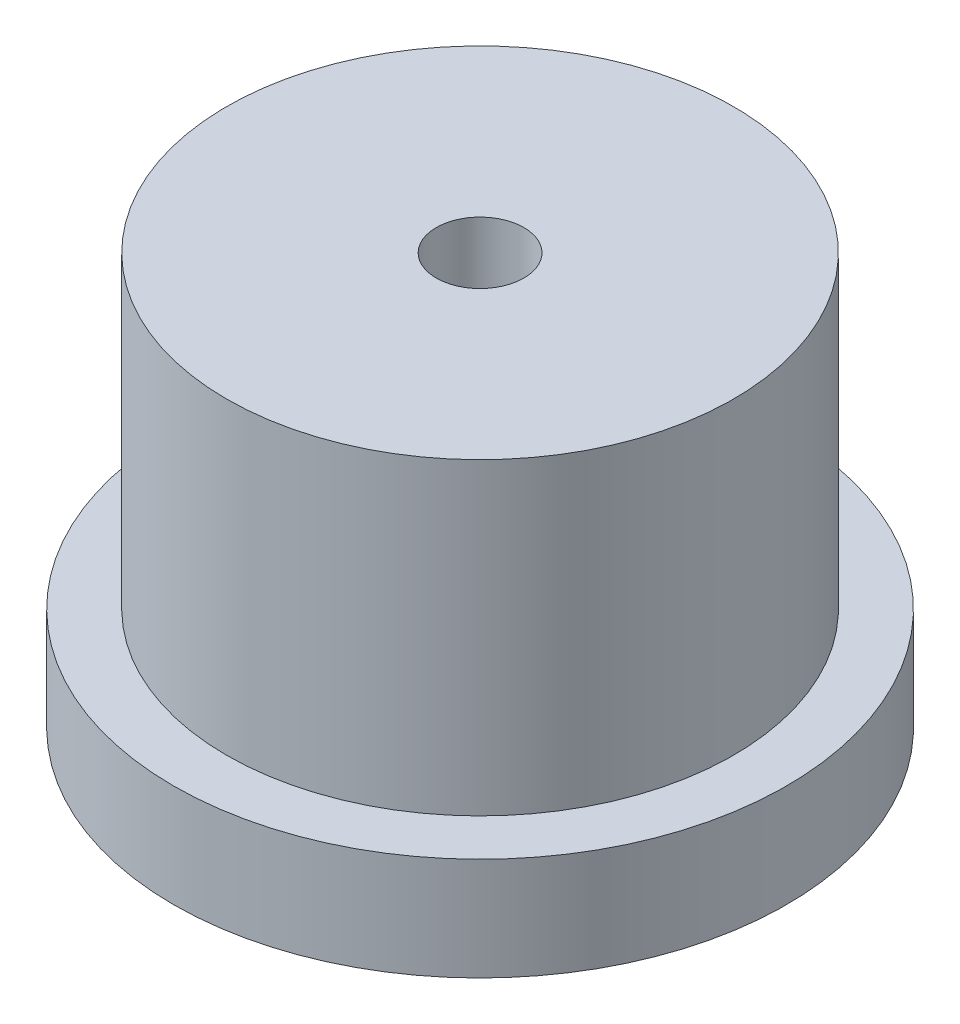
from build123d import *

# Parameters (mm, degrees)
SKETCH1_R             = 9.4615
EXTRUDE1_DEPTH        = 3.175
SKETCH2_R             = 7.8232
EXTRUDE2_DEPTH        = 9.525
F_6_32_TAPPED_HOLE2_D = 2.7051


with BuildPart() as part:
    # Sketch1 → Extrude1 (new body)
    with BuildSketch(Plane(origin=(0, 0, 0), x_dir=(1, 0, 0), z_dir=(0, 1, 0))):
        with Locations(Location((0, 0, 0), (0, 0, 270))):  # turned: the seam where the file's is
            Circle(SKETCH1_R)
    extrude(amount=EXTRUDE1_DEPTH)

    # Sketch2 → Extrude2 (add)
    with BuildSketch(Plane(origin=(0, 3.175, 0), x_dir=(1, 0, 0), z_dir=(0, 1, 0))):
        with Locations(Location((0, 0, 0), (0, 0, 270))):  # turned: the seam where the file's is
            Circle(SKETCH2_R)
    extrude(amount=EXTRUDE2_DEPTH)

    # #6-32 Tapped Hole2 (through all)
    with Locations(Plane(origin=(0, 0, 0), x_dir=(0, 0, -1), z_dir=(0, -1, 0))):
        with Locations((0, 0)):
            Hole(F_6_32_TAPPED_HOLE2_D / 2)


solid = part.part
